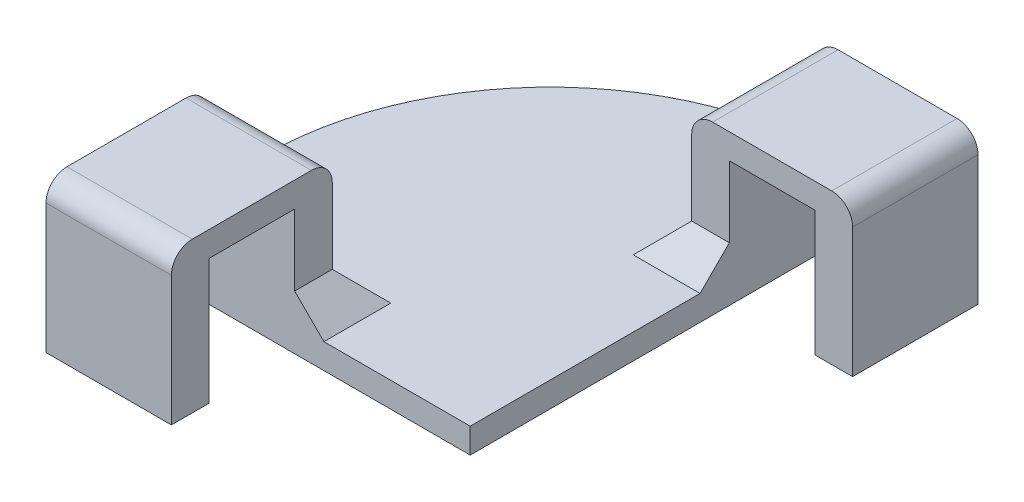
from build123d import *

# Parameters (mm, degrees)
SKETCH1_W           = 30
SKETCH1_H           = 9
SKETCH1_W_2         = 9
SKETCH1_H_2         = 30
BOSS_EXTRUDE1_DEPTH = 6
BOSS_EXTRUDE2_START = 6
SKETCH1_3_W         = 30
SKETCH1_3_H         = 9
SKETCH1_3_W_2       = 9
SKETCH1_3_H_2       = 30
BOSS_EXTRUDE2_DEPTH = 24
BOSS_EXTRUDE3_START = 30
SKETCH1_4_W         = 30
SKETCH1_4_H         = 9
SKETCH1_4_H_2       = 20.5
SKETCH1_4_W_2       = 9
SKETCH1_4_H_3       = 30
SKETCH1_4_W_3       = 20.5
BOSS_EXTRUDE3_DEPTH = 6
BOSS_EXTRUDE4_START = 30
SKETCH1_5_W         = 30
SKETCH1_5_H         = 9
SKETCH1_5_W_2       = 9
SKETCH1_5_H_2       = 30
BOSS_EXTRUDE4_DEPTH = 30
CHAMFER1_SIZE       = 7
FILLET1_R           = 5


with BuildPart() as part:
    # Sketch1 → Boss-Extrude1 (new body)
    with BuildSketch(Plane(origin=(0, 0, 0), x_dir=(1, 0, 0), z_dir=(0, 1, 0))):
        with Locations((-57, 4.5)):
            Rectangle(SKETCH1_W, SKETCH1_H)
        with Locations((-4.5, 77)):
            Rectangle(SKETCH1_W_2, SKETCH1_H_2)
        with BuildLine():
            Line((0, 99.896112213), (-12.24628833, 99.896112213))
            ThreePointArc((-12.24628833, 99.896112213), (-60.703064532, 79.824658322), (-80.774518424, 31.36788212))
            Line((-80.774518424, 31.36788212), (-80.774518424, 0))
            Line((-80.774518424, 0), (-72, 0))
            Line((-72, 0), (-72, 9))
            Line((-72, 9), (-42, 9))
            Line((-42, 9), (-42, 0))
            Line((-42, 0), (0, 0))
            Line((0, 0), (0, 62))
            Line((0, 62), (-9, 62))
            Line((-9, 62), (-9, 92))
            Line((-9, 92), (0, 92))
            Line((0, 92), (0, 99.896112213))
        make_face()
    extrude(amount=BOSS_EXTRUDE1_DEPTH)

    # Sketch1_3 → Boss-Extrude2 (add)
    with BuildSketch(Plane(origin=(0, 0, 0), x_dir=(1, 0, 0), z_dir=(0, 1, 0)).offset(BOSS_EXTRUDE2_START)):
        with Locations((-57, 4.5)):
            Rectangle(SKETCH1_3_W, SKETCH1_3_H)
        with Locations((-4.5, 77)):
            Rectangle(SKETCH1_3_W_2, SKETCH1_3_H_2)
    extrude(amount=BOSS_EXTRUDE2_DEPTH)

    # Sketch1_4 → Boss-Extrude3 (add)
    with BuildSketch(Plane(origin=(0, 0, 0), x_dir=(1, 0, 0), z_dir=(0, 1, 0)).offset(BOSS_EXTRUDE3_START)):
        with Locations((-57, 4.5)):
            Rectangle(SKETCH1_4_W, SKETCH1_4_H)
        with Locations((-57, -10.25)):
            Rectangle(SKETCH1_4_W, SKETCH1_4_H_2)
        with Locations((-57, -25)):
            Rectangle(SKETCH1_4_W, SKETCH1_4_H)
        with Locations((-4.5, 77)):
            Rectangle(SKETCH1_4_W_2, SKETCH1_4_H_3)
        with Locations((10.25, 77)):
            Rectangle(SKETCH1_4_W_3, SKETCH1_4_H_3)
        with Locations((25, 77)):
            Rectangle(SKETCH1_4_W_2, SKETCH1_4_H_3)
    extrude(amount=BOSS_EXTRUDE3_DEPTH)

    # Sketch1_5 → Boss-Extrude4 (add)
    with BuildSketch(Plane(origin=(0, 0, 0), x_dir=(1, 0, 0), z_dir=(0, 1, 0)).offset(BOSS_EXTRUDE4_START)):
        with Locations((-57, -25)):
            Rectangle(SKETCH1_5_W, SKETCH1_5_H)
        with Locations((25, 77)):
            Rectangle(SKETCH1_5_W_2, SKETCH1_5_H_2)
    extrude(amount=-BOSS_EXTRUDE4_DEPTH)

    # Chamfer1
    chamfer1_edges = [part.edges().sort_by_distance(p)[0] for p in [
        (-42, 6, -4.5),
        (-72, 6, -4.5),
        (-57, 6, -9),
        (-4.5, 6, -92),
        (-4.5, 6, -62),
        (-9, 6, -77),
    ]]
    chamfer(chamfer1_edges, length=CHAMFER1_SIZE)

    # Fillet1
    fillet1_edges = [part.edges().sort_by_distance(p)[0] for p in [
        (-57, 36, -9),
        (-57, 36, 29.5),
        (29.5, 36, -77),
        (-9, 36, -77),
    ]]
    fillet(fillet1_edges, radius=FILLET1_R)


solid = part.part
